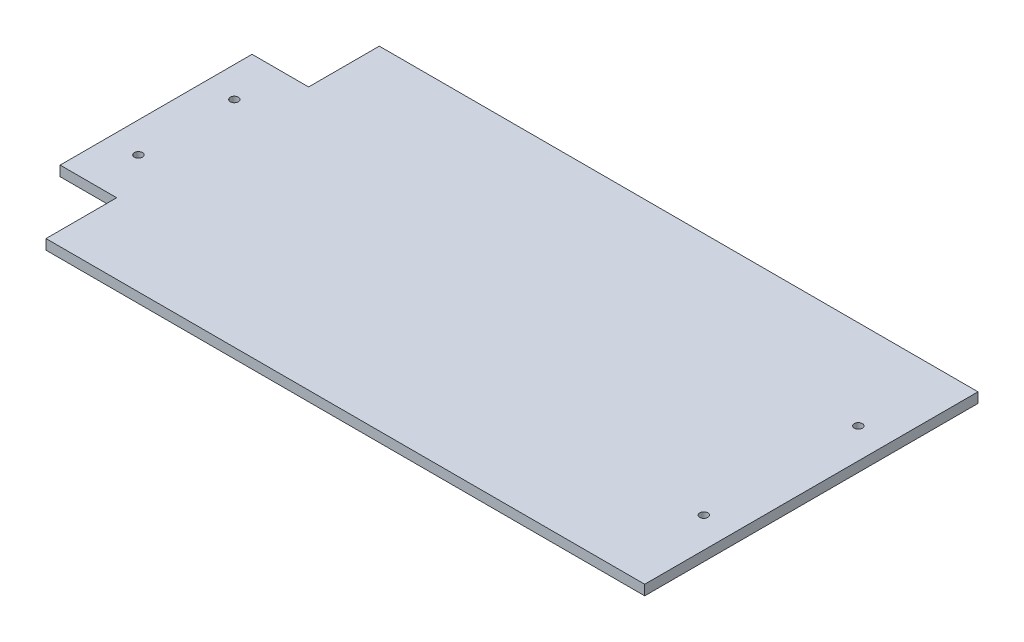
from build123d import *

# Parameters (mm, degrees)
BOSS_EXTRUDE1_DEPTH = 5
SKETCH2_R           = 2
CUT_EXTRUDE1_DEPTH  = 5


with BuildPart() as part:
    # Sketch1 → Boss-Extrude1 (new body)
    with BuildSketch(Plane(origin=(0, 0, 0), x_dir=(1, 0, 0), z_dir=(0, 1, 0))):
        Polygon((162.2, -82.5), (162.2, 82.5), (-134.2, 82.5), (-134.2, 47.5), (-162.2, 47.5), (-162.2, -47.5), (-134.2, -47.5), (-134.2, -82.5), align=None)
    extrude(amount=BOSS_EXTRUDE1_DEPTH)

    # Sketch2 → Cut-Extrude1 (cut)
    with BuildSketch(Plane(origin=(0, 5, 0), x_dir=(1, 0, 0), z_dir=(0, 1, 0))):
        with Locations((-147.2, 23.75)):
            Circle(SKETCH2_R)
        with Locations((147.2, 38.25)):
            Circle(SKETCH2_R)
        with Locations((147.2, -38.25)):
            Circle(SKETCH2_R)
        with Locations((-147.2, -23.75)):
            Circle(SKETCH2_R)
    extrude(amount=-CUT_EXTRUDE1_DEPTH, mode=Mode.SUBTRACT)


solid = part.part
